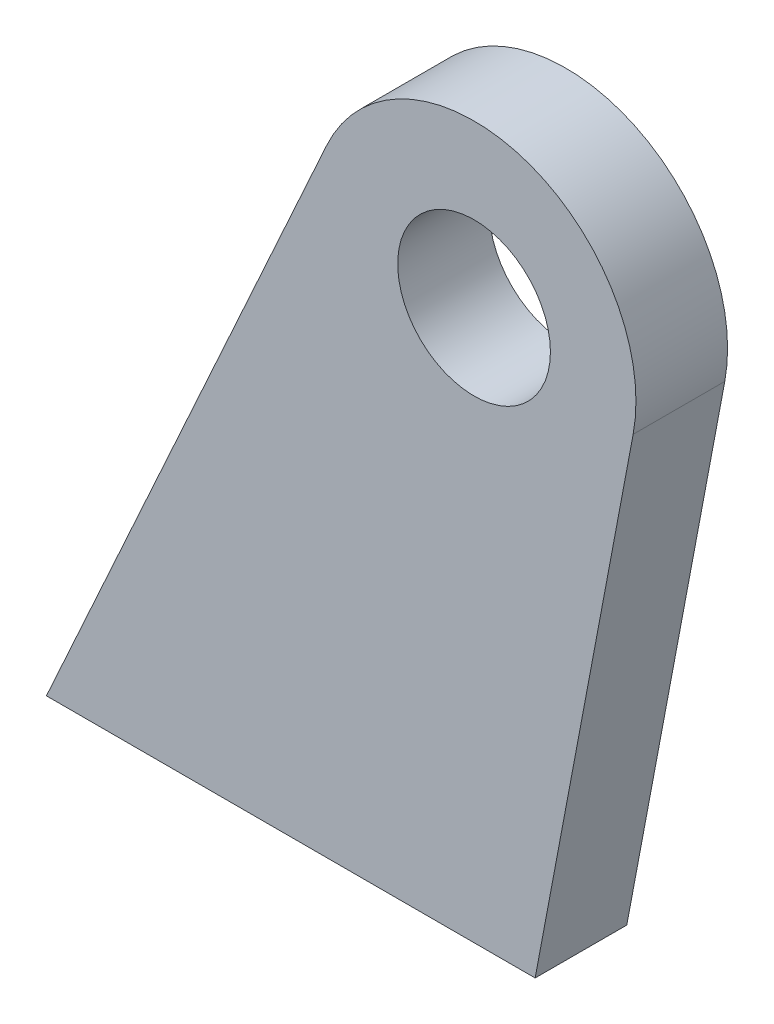
from build123d import *

# Parameters (mm, degrees)
SKETCH1_R           = 15.875
BOSS_EXTRUDE1_DEPTH = 19.05


with BuildPart() as part:
    # Sketch1 → Boss-Extrude1 (new body)
    with BuildSketch(Plane.XY):
        with BuildLine():
            Line((33.072437746, -6.234812473), (12.7, -114.3))
            Line((12.7, -114.3), (-88.9, -114.3))
            Line((-88.9, -114.3), (-30.640469546, 13.921948535))
            ThreePointArc((-30.640469546, 13.921948535), (10.151471367, 32.087484384), (33.072437746, -6.234812473))
        make_face()
        Circle(SKETCH1_R, mode=Mode.SUBTRACT)
    extrude(amount=BOSS_EXTRUDE1_DEPTH)


solid = part.part
